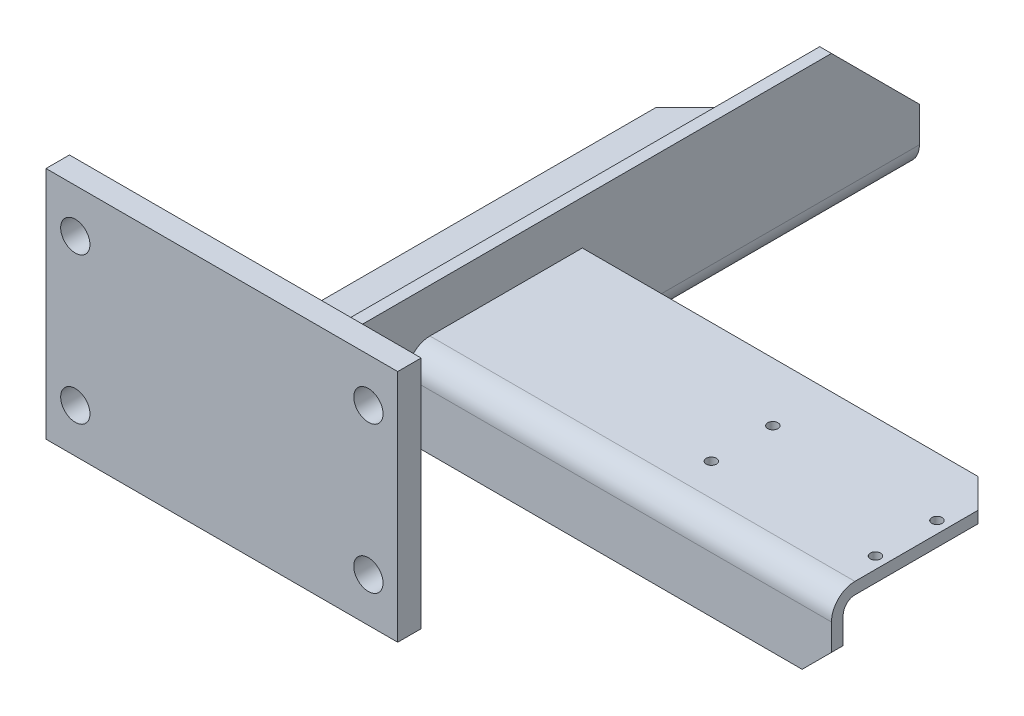
from build123d import *

# Parameters (mm, degrees)
SKETCH_1_W          = 120
SKETCH_1_H          = 80
EXTRUDE_1_DEPTH     = 8
CUT_EXTRUDE_1_REACH = 10
SKETCH_2_R          = 5
EXTRUDE_2_DEPTH     = 200
CHAMFER_1_SIZE      = 30
CUT_EXTRUDE_3_REACH = 62
SKETCH_5_R          = 5
EXTRUDE_3_DEPTH     = 145
CHAMFER_2_SIZE      = 10
CUT_EXTRUDE_4_REACH = 57
SKETCH_7_R          = 1.75


with BuildPart() as part:
    # 草图1 → 凸台-拉伸1 (new body)
    with BuildSketch(Plane.XY):
        with Locations((60, 40)):
            Rectangle(SKETCH_1_W, SKETCH_1_H)
    extrude(amount=EXTRUDE_1_DEPTH)

    # 草图2 → 切除-拉伸1 (cut, up to next)
    with BuildSketch(Plane.XY.offset(8), mode=Mode.PRIVATE) as cut_extrude_1_sk1:
        with Locations((10, 65)):
            Circle(SKETCH_2_R)
    cut_extrude_1_tool1 = extrude(cut_extrude_1_sk1.sketch, amount=-CUT_EXTRUDE_1_REACH, mode=Mode.PRIVATE) & part.part
    add(cut_extrude_1_tool1.solids().sort_by_distance((10, 65, 8))[0], mode=Mode.SUBTRACT)
    # 草图2 → 切除-拉伸1 (cut, up to next)
    with BuildSketch(Plane.XY.offset(8), mode=Mode.PRIVATE) as cut_extrude_1_sk2:
        with Locations((10, 15)):
            Circle(SKETCH_2_R)
    cut_extrude_1_tool2 = extrude(cut_extrude_1_sk2.sketch, amount=-CUT_EXTRUDE_1_REACH, mode=Mode.PRIVATE) & part.part
    add(cut_extrude_1_tool2.solids().sort_by_distance((10, 15, 8))[0], mode=Mode.SUBTRACT)
    # 草图2 → 切除-拉伸1 (cut, up to next)
    with BuildSketch(Plane.XY.offset(8), mode=Mode.PRIVATE) as cut_extrude_1_sk3:
        with Locations((110, 15)):
            Circle(SKETCH_2_R)
    cut_extrude_1_tool3 = extrude(cut_extrude_1_sk3.sketch, amount=-CUT_EXTRUDE_1_REACH, mode=Mode.PRIVATE) & part.part
    add(cut_extrude_1_tool3.solids().sort_by_distance((110, 15, 8))[0], mode=Mode.SUBTRACT)
    # 草图2 → 切除-拉伸1 (cut, up to next)
    with BuildSketch(Plane.XY.offset(8), mode=Mode.PRIVATE) as cut_extrude_1_sk4:
        with Locations((110, 65)):
            Circle(SKETCH_2_R)
    cut_extrude_1_tool4 = extrude(cut_extrude_1_sk4.sketch, amount=-CUT_EXTRUDE_1_REACH, mode=Mode.PRIVATE) & part.part
    add(cut_extrude_1_tool4.solids().sort_by_distance((110, 65, 8))[0], mode=Mode.SUBTRACT)

    # 草图3 → 凸台-拉伸2 (add)
    with BuildSketch(Plane(origin=(0, 0, 0), x_dir=(-1, 0, 0), z_dir=(0, 0, -1))):
        with BuildLine():
            Line((-30, 20), (-82, 20))
            ThreePointArc((-82, 20), (-87.656854249, 22.343145751), (-90, 28))
            Line((-90, 28), (-90, 70))
            Line((-90, 70), (-86, 70))
            Line((-86, 70), (-86, 27.966747679))
            ThreePointArc((-86, 27.966747679), (-84.828427125, 25.138320554), (-82, 23.966747679))
            Line((-82, 23.966747679), (-30, 23.966747679))
            Line((-30, 23.966747679), (-30, 20))
        make_face()
    extrude(amount=EXTRUDE_2_DEPTH)

    # 倒角1
    chamfer_1_edges = [part.edges().sort_by_distance(p)[0] for p in [
        (30, 21.983373839, -200),
        (88, 70, -200),
    ]]
    chamfer(chamfer_1_edges, length=CHAMFER_1_SIZE)

    # 草图5 → 切除-拉伸3 (cut, up to next)
    with BuildSketch(Plane.XZ.offset(-20), mode=Mode.PRIVATE) as cut_extrude_3_sk1:
        with Locations((60, -70)):
            Circle(SKETCH_5_R)
    cut_extrude_3_tool1 = extrude(cut_extrude_3_sk1.sketch, amount=-CUT_EXTRUDE_3_REACH, mode=Mode.PRIVATE) & part.part
    add(cut_extrude_3_tool1.solids().sort_by_distance((60, 20, -70))[0], mode=Mode.SUBTRACT)
    # 草图5 → 切除-拉伸3 (cut, up to next)
    with BuildSketch(Plane.XZ.offset(-20), mode=Mode.PRIVATE) as cut_extrude_3_sk2:
        with Locations((60, -120)):
            Circle(SKETCH_5_R)
    cut_extrude_3_tool2 = extrude(cut_extrude_3_sk2.sketch, amount=-CUT_EXTRUDE_3_REACH, mode=Mode.PRIVATE) & part.part
    add(cut_extrude_3_tool2.solids().sort_by_distance((60, 20, -120))[0], mode=Mode.SUBTRACT)

    # 草图6 → 凸台-拉伸3 (add)
    with BuildSketch(Plane(origin=(90, 0, 0), x_dir=(0, 0, -1), z_dir=(1, 0, 0))):
        with BuildLine():
            Line((25, 47), (25, 28))
            Line((25, 28), (29, 28))
            Line((29, 28), (29, 47))
            ThreePointArc((29, 47), (30.171572875, 49.828427125), (33, 51))
            Line((33, 51), (85, 51))
            Line((85, 51), (85, 55))
            Line((85, 55), (33, 55))
            ThreePointArc((33, 55), (27.343145751, 52.656854249), (25, 47))
        make_face()
    extrude(amount=EXTRUDE_3_DEPTH)

    # 倒角2
    chamfer_2_edges = [part.edges().sort_by_distance(p)[0] for p in [
        (235, 53, -85),
        (235, 28, -27),
    ]]
    chamfer(chamfer_2_edges, length=CHAMFER_2_SIZE)

    # 草图7 → 切除-拉伸4 (cut, up to next)
    with BuildSketch(Plane(origin=(0, 55, 0), x_dir=(1, 0, 0), z_dir=(0, 1, 0)), mode=Mode.PRIVATE) as cut_extrude_4_sk1:
        with Locations((231, 65)):
            Circle(SKETCH_7_R)
    cut_extrude_4_tool1 = extrude(cut_extrude_4_sk1.sketch, amount=-CUT_EXTRUDE_4_REACH, mode=Mode.PRIVATE) & part.part
    add(cut_extrude_4_tool1.solids().sort_by_distance((231, 55, -65))[0], mode=Mode.SUBTRACT)
    # 草图7 → 切除-拉伸4 (cut, up to next)
    with BuildSketch(Plane(origin=(0, 55, 0), x_dir=(1, 0, 0), z_dir=(0, 1, 0)), mode=Mode.PRIVATE) as cut_extrude_4_sk2:
        with Locations((231, 44)):
            Circle(SKETCH_7_R)
    cut_extrude_4_tool2 = extrude(cut_extrude_4_sk2.sketch, amount=-CUT_EXTRUDE_4_REACH, mode=Mode.PRIVATE) & part.part
    add(cut_extrude_4_tool2.solids().sort_by_distance((231, 55, -44))[0], mode=Mode.SUBTRACT)
    # 草图7 → 切除-拉伸4 (cut, up to next)
    with BuildSketch(Plane(origin=(0, 55, 0), x_dir=(1, 0, 0), z_dir=(0, 1, 0)), mode=Mode.PRIVATE) as cut_extrude_4_sk3:
        with Locations((175, 44)):
            Circle(SKETCH_7_R)
    cut_extrude_4_tool3 = extrude(cut_extrude_4_sk3.sketch, amount=-CUT_EXTRUDE_4_REACH, mode=Mode.PRIVATE) & part.part
    add(cut_extrude_4_tool3.solids().sort_by_distance((175, 55, -44))[0], mode=Mode.SUBTRACT)
    # 草图7 → 切除-拉伸4 (cut, up to next)
    with BuildSketch(Plane(origin=(0, 55, 0), x_dir=(1, 0, 0), z_dir=(0, 1, 0)), mode=Mode.PRIVATE) as cut_extrude_4_sk4:
        with Locations((175, 65)):
            Circle(SKETCH_7_R)
    cut_extrude_4_tool4 = extrude(cut_extrude_4_sk4.sketch, amount=-CUT_EXTRUDE_4_REACH, mode=Mode.PRIVATE) & part.part
    add(cut_extrude_4_tool4.solids().sort_by_distance((175, 55, -65))[0], mode=Mode.SUBTRACT)


solid = part.part
